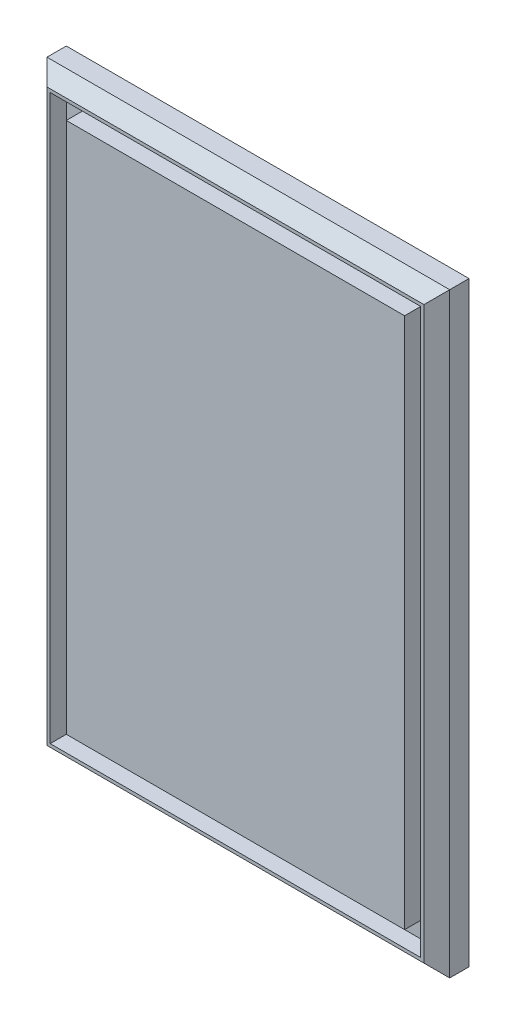
from build123d import *

# Parameters (mm, degrees)
SKETCH_1_W          = 250
SKETCH_1_H          = 370
EXTRUDE_1_DEPTH     = 20
CHAMFER_1_SIZE      = 8
SKETCH_2_W          = 230
SKETCH_2_H          = 350
SKETCH_2_W_2        = 210
SKETCH_2_H_2        = 330
CUT_EXTRUDE_1_DEPTH = 10


with BuildPart() as part:
    # Эскиз1 → Бобышка-Вытянуть1 (new body)
    with BuildSketch(Plane.XY):
        Rectangle(SKETCH_1_W, SKETCH_1_H)
    extrude(amount=EXTRUDE_1_DEPTH)

    # Фаска1
    chamfer_1_edges = [part.edges().sort_by_distance(p)[0] for p in [
        (0, -185, 20),
        (-125, 0, 20),
        (0, 185, 20),
        (125, 0, 20),
    ]]
    chamfer(chamfer_1_edges, length=CHAMFER_1_SIZE)

    # Эскиз2 → Вырез-Вытянуть1 (cut)
    with BuildSketch(Plane.XY.offset(20)):
        Rectangle(SKETCH_2_W, SKETCH_2_H)
        Rectangle(SKETCH_2_W_2, SKETCH_2_H_2, mode=Mode.SUBTRACT)
    extrude(amount=-CUT_EXTRUDE_1_DEPTH, mode=Mode.SUBTRACT)


solid = part.part
